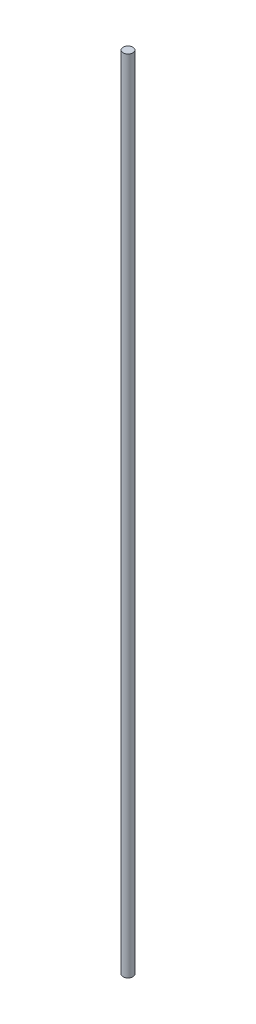
from build123d import *

# Parameters (mm, degrees)
SKETCH1_R           = 1.397
BOSS_EXTRUDE1_DEPTH = 228.6


with BuildPart() as part:
    # Sketch1 → Boss-Extrude1 (new body)
    with BuildSketch(Plane(origin=(0, 0, 0), x_dir=(1, 0, 0), z_dir=(0, 1, 0))):
        Circle(SKETCH1_R)
    extrude(amount=BOSS_EXTRUDE1_DEPTH)


solid = part.part
